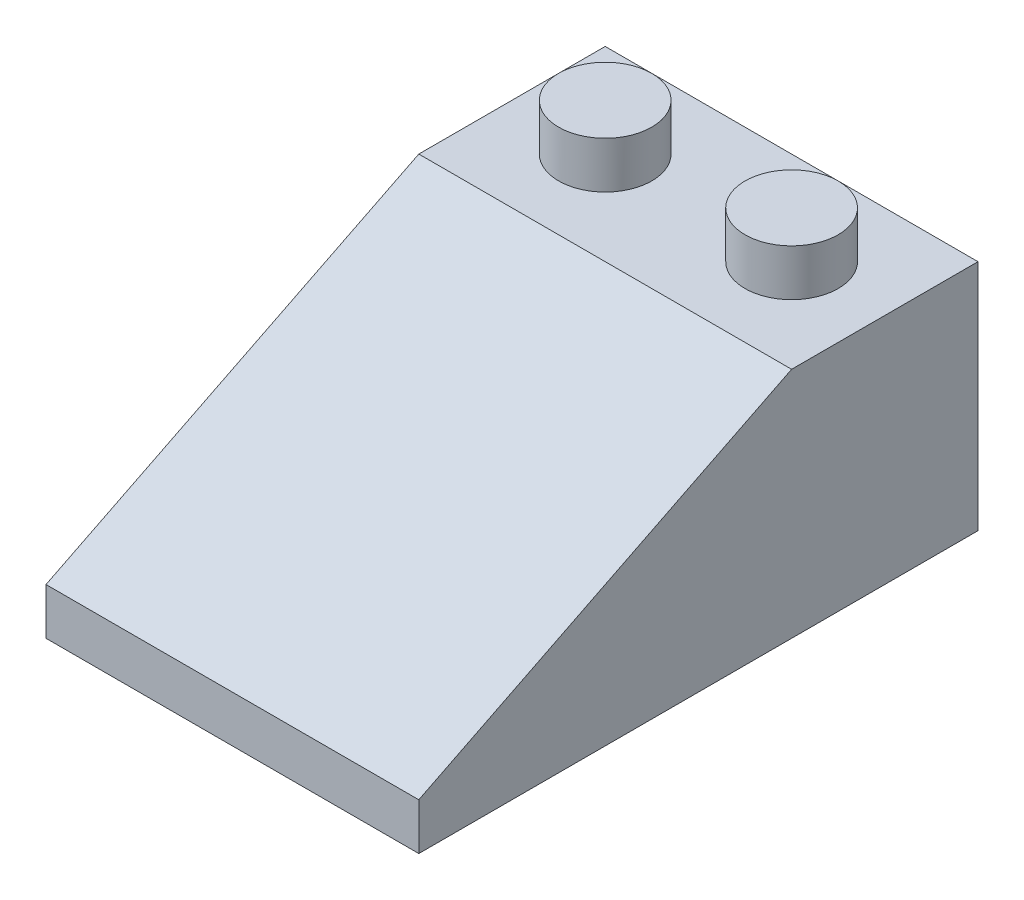
from build123d import *

# Parameters (mm, degrees)
BOSS_EXTRUDE1_DEPTH = 8
SKETCH2_R           = 2
BOSS_EXTRUDE2_DEPTH = 2
SHELL1_T            = -1
BOSS_EXTRUDE3_REACH = 12
SKETCH3_R           = 2.7
SKETCH3_R_2         = 1.7


with BuildPart() as part:
    # Sketch1 → Boss-Extrude1 (new body, symmetric)
    with BuildSketch(Plane(origin=(0, 0, 0), x_dir=(0, 0, -1), z_dir=(1, 0, 0))):
        Polygon((0, 0), (0, -2), (24, -2), (24, 8), (16, 8), align=None)
    extrude(amount=BOSS_EXTRUDE1_DEPTH, both=True)

    # Sketch2 → Boss-Extrude2 (add)
    with BuildSketch(Plane(origin=(0, 8, 0), x_dir=(1, 0, 0), z_dir=(0, 1, 0))):
        with Locations((-4, 20)):
            Circle(SKETCH2_R)
        with Locations((4, 20)):
            Circle(SKETCH2_R)
    extrude(amount=BOSS_EXTRUDE2_DEPTH)

    # Shell1
    shell1_openings = [part.faces().sort_by_distance(p)[0] for p in [
        (0, -2, -12),
    ]]
    offset(amount=SHELL1_T, openings=shell1_openings, kind=Kind.INTERSECTION)

    # Sketch3 → Boss-Extrude3 (add, up to next)
    with BuildSketch(Plane(origin=(0, 0, 0), x_dir=(1, 0, 0), z_dir=(0, 1, 0)), mode=Mode.PRIVATE) as boss_extrude3_sk1:
        with Locations((0, 8)):
            Circle(SKETCH3_R)
        with Locations((0, 8)):
            Circle(SKETCH3_R_2, mode=Mode.SUBTRACT)
    boss_extrude3_tool1 = extrude(boss_extrude3_sk1.sketch, amount=BOSS_EXTRUDE3_REACH, mode=Mode.PRIVATE) - part.part
    add(boss_extrude3_tool1.solids().sort_by_distance((-2.623632, 0, -8))[0])
    # Sketch3 → Boss-Extrude3 (add, up to next)
    with BuildSketch(Plane(origin=(0, 0, 0), x_dir=(1, 0, 0), z_dir=(0, 1, 0)), mode=Mode.PRIVATE) as boss_extrude3_sk2:
        with Locations((0, 16)):
            Circle(SKETCH3_R)
        with Locations((0, 16)):
            Circle(SKETCH3_R_2, mode=Mode.SUBTRACT)
    boss_extrude3_tool2 = extrude(boss_extrude3_sk2.sketch, amount=BOSS_EXTRUDE3_REACH, mode=Mode.PRIVATE) - part.part
    add(boss_extrude3_tool2.solids().sort_by_distance((-2.623632, 0, -16))[0])


solid = part.part
